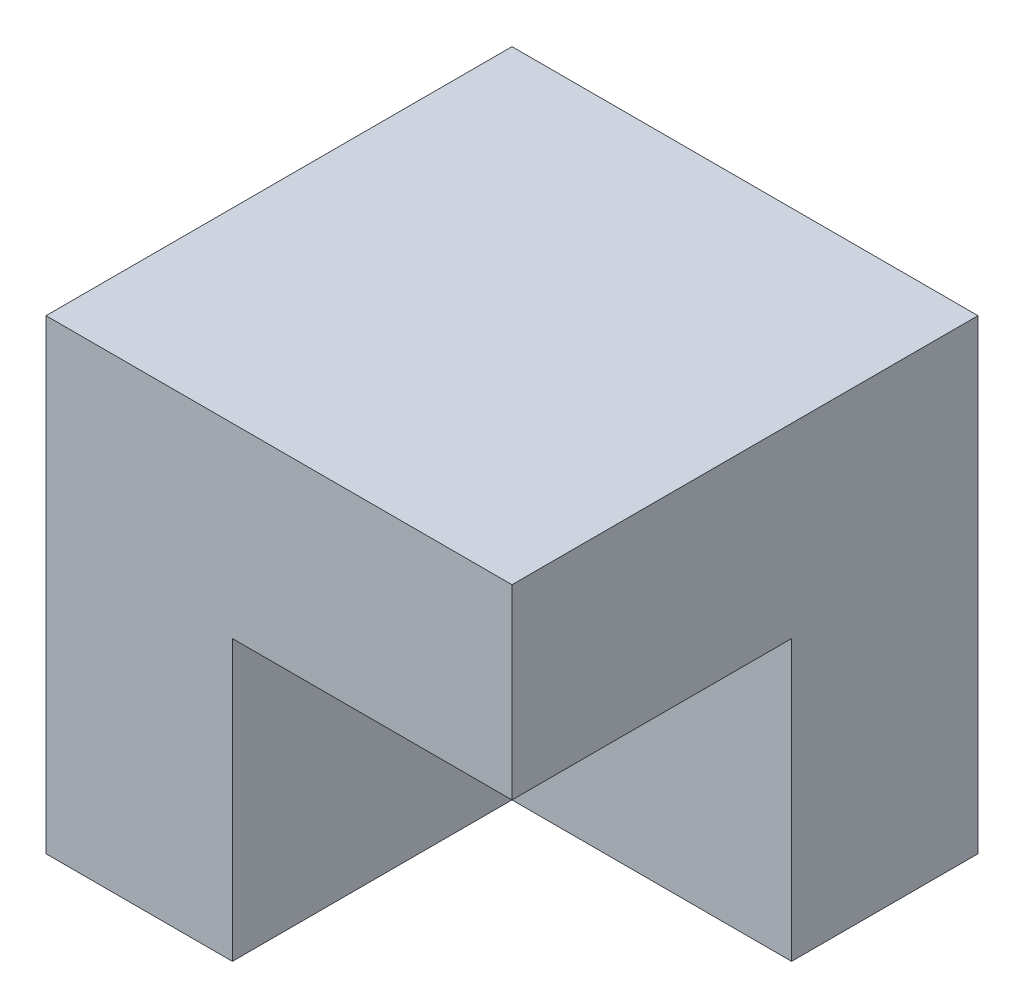
from build123d import *

# Parameters (mm, degrees)
SKETCH1_W           = 5
SKETCH1_H           = 5
BOSS_EXTRUDE1_DEPTH = 5
SKETCH2_W           = 3
SKETCH2_H           = 3
CUT_EXTRUDE1_DEPTH  = 3


with BuildPart() as part:
    # Sketch1 → Boss-Extrude1 (new body)
    with BuildSketch(Plane(origin=(0, 0, 0), x_dir=(1, 0, 0), z_dir=(0, 1, 0))):
        Rectangle(SKETCH1_W, SKETCH1_H)
    extrude(amount=BOSS_EXTRUDE1_DEPTH)

    # Sketch2 → Cut-Extrude1 (cut)
    with BuildSketch(Plane(origin=(0, 0, 0), x_dir=(1, 0, 0), z_dir=(0, 1, 0))):
        with Locations((1, -1)):
            Rectangle(SKETCH2_W, SKETCH2_H)
    extrude(amount=CUT_EXTRUDE1_DEPTH, mode=Mode.SUBTRACT)


solid = part.part
